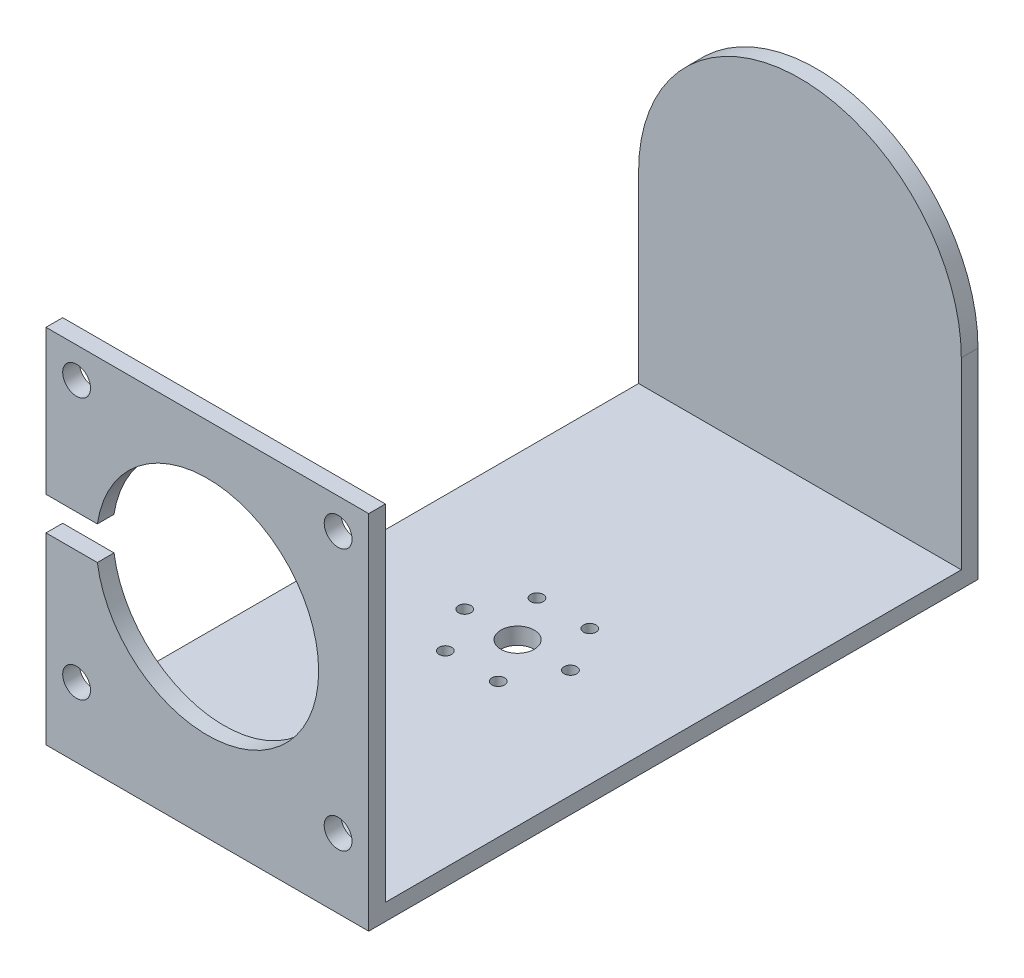
from build123d import *

# Parameters (mm, degrees)
BOSS_EXTRUDE1_DEPTH       = 58
SKETCH2_R                 = 2.5
SKETCH2_R_2               = 20
CUT_EXTRUDE1_DEPTH        = 58
CUT_EXTRUDE2_DEPTH        = 58
CUT_EXTRUDE3_DEPTH        = 58
SKETCH5_R                 = 2.95
BOSS_EXTRUDE2_DEPTH       = 8
SKETCH7_W                 = 29
SKETCH7_H                 = 6
CUT_EXTRUDE5_DEPTH        = 10
F_4_40_TAPPED_HOLE4_D     = 2.2606
F_4_40_TAPPED_HOLE4_DEPTH = 7.6
F_4_40_TAPPED_HOLE4_TIP   = 0.679152758
SKETCH25_R                = 3
CUT_EXTRUDE6_DEPTH        = 10
SKETCH26_W                = 103.5
SKETCH26_H                = 2
CUT_EXTRUDE7_DEPTH        = 90


with BuildPart() as part:
    # Sketch1 → Boss-Extrude1 (new body)
    with BuildSketch(Plane(origin=(0, 0, 0), x_dir=(0, 0, -1), z_dir=(1, 0, 0))):
        Polygon((-73.351671883, 30.400809615), (-73.351671883, -29.599190385), (30.148328117, -29.599190385), (30.148328117, 30.400809615), (33.148328117, 30.400809615), (33.148328117, -34.599190385), (-76.351671883, -34.599190385), (-76.351671883, 30.400809615), align=None)
    extrude(amount=BOSS_EXTRUDE1_DEPTH)

    # Sketch2 → Cut-Extrude1 (cut)
    with BuildSketch(Plane.XY.offset(76.351671883)):
        with Locations((5.5, 24.900809615)):
            Circle(SKETCH2_R)
        with Locations((52.5, 24.900809615)):
            Circle(SKETCH2_R)
        with Locations((52.5, -22.099190385)):
            Circle(SKETCH2_R)
        with Locations((5.5, -22.099190385)):
            Circle(SKETCH2_R)
        with Locations((29, 1.400809615)):
            Circle(SKETCH2_R_2)
    extrude(amount=-CUT_EXTRUDE1_DEPTH, mode=Mode.SUBTRACT)

    # Sketch3 → Cut-Extrude2 (cut)
    with BuildSketch(Plane(origin=(0, 0, -33.148328117), x_dir=(-1, 0, 0), z_dir=(0, 0, -1))):
        with BuildLine():
            Line((-29, 30.400809615), (-58, 30.400809615))
            Line((-58, 30.400809615), (-58, 1.400809615))
            ThreePointArc((-58, 1.400809615), (-49.506096654, 21.90690627), (-29, 30.400809615))
        make_face()
    extrude(amount=-CUT_EXTRUDE2_DEPTH, mode=Mode.SUBTRACT)

    # Sketch4 → Cut-Extrude3 (cut)
    with BuildSketch(Plane(origin=(0, 0, -33.148328117), x_dir=(-1, 0, 0), z_dir=(0, 0, -1))):
        with BuildLine():
            Line((-29, 30.400809615), (0, 30.400809615))
            Line((0, 30.400809615), (0, 1.400809615))
            ThreePointArc((0, 1.400809615), (-8.493903346, 21.90690627), (-29, 30.400809615))
        make_face()
    extrude(amount=-CUT_EXTRUDE3_DEPTH, mode=Mode.SUBTRACT)

    # Sketch5 → Boss-Extrude2 (add)
    with BuildSketch(Plane(origin=(0, 0, -33.148328117), x_dir=(-1, 0, 0), z_dir=(0, 0, -1))):
        with Locations((-29, 1.400809615)):
            Circle(SKETCH5_R)
    extrude(amount=BOSS_EXTRUDE2_DEPTH)

    # Sketch7 → Cut-Extrude5 (cut)
    with BuildSketch(Plane.XY.offset(76.351671883)):
        with Locations((14.5, 1.400809615)):
            Rectangle(SKETCH7_W, SKETCH7_H)
    extrude(amount=-CUT_EXTRUDE5_DEPTH, mode=Mode.SUBTRACT)

    # #4-40 Tapped Hole4
    with Locations(Plane(origin=(0, -34.599190385, 0), x_dir=(-1, 0, 0), z_dir=(0, -1, 0))):
        with Locations((-19.5, -20.601671883), (-24.25, -28.828913219), (-33.75, -28.828913219), (-38.5, -20.601671883), (-33.75, -12.374430547), (-24.25, -12.374430547)):
            Hole(F_4_40_TAPPED_HOLE4_D / 2, depth=F_4_40_TAPPED_HOLE4_DEPTH)
            with Locations((0, 0, -(F_4_40_TAPPED_HOLE4_DEPTH + F_4_40_TAPPED_HOLE4_TIP / 2))):  # 118° drill point
                Cone(0, F_4_40_TAPPED_HOLE4_D / 2, F_4_40_TAPPED_HOLE4_TIP, mode=Mode.SUBTRACT)

    # Sketch25 → Cut-Extrude6 (cut)
    with BuildSketch(Plane.XZ.offset(34.599190385)):
        with Locations((29, 20.601671883)):
            Circle(SKETCH25_R)
    extrude(amount=-CUT_EXTRUDE6_DEPTH, mode=Mode.SUBTRACT)

    # Sketch26 → Cut-Extrude7 (cut)
    with BuildSketch(Plane(origin=(58, 0, 0), x_dir=(0, 0, -1), z_dir=(1, 0, 0))):
        with Locations((-21.601671883, -30.599190385)):
            Rectangle(SKETCH26_W, SKETCH26_H)
    extrude(amount=-CUT_EXTRUDE7_DEPTH, mode=Mode.SUBTRACT)


solid = part.part
